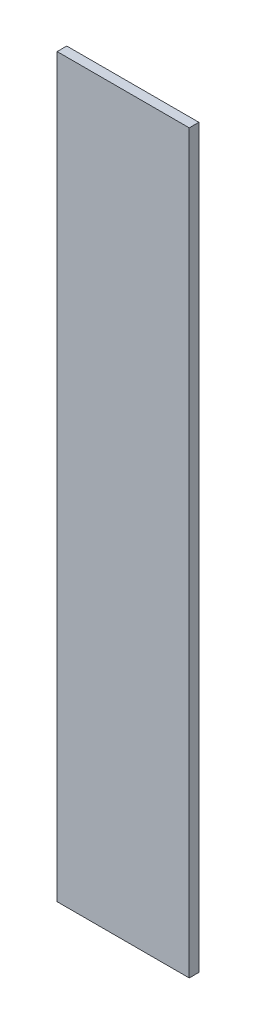
from build123d import *

# Parameters (mm, degrees)
SKETCH1_W           = 68
SKETCH1_H           = 378.959461552
BOSS_EXTRUDE1_DEPTH = 4.953


with BuildPart() as part:
    # Sketch1 → Boss-Extrude1 (new body)
    with BuildSketch(Plane.XY):
        with Locations((0, 205.479730776)):
            Rectangle(SKETCH1_W, SKETCH1_H)
    extrude(amount=BOSS_EXTRUDE1_DEPTH)


solid = part.part
